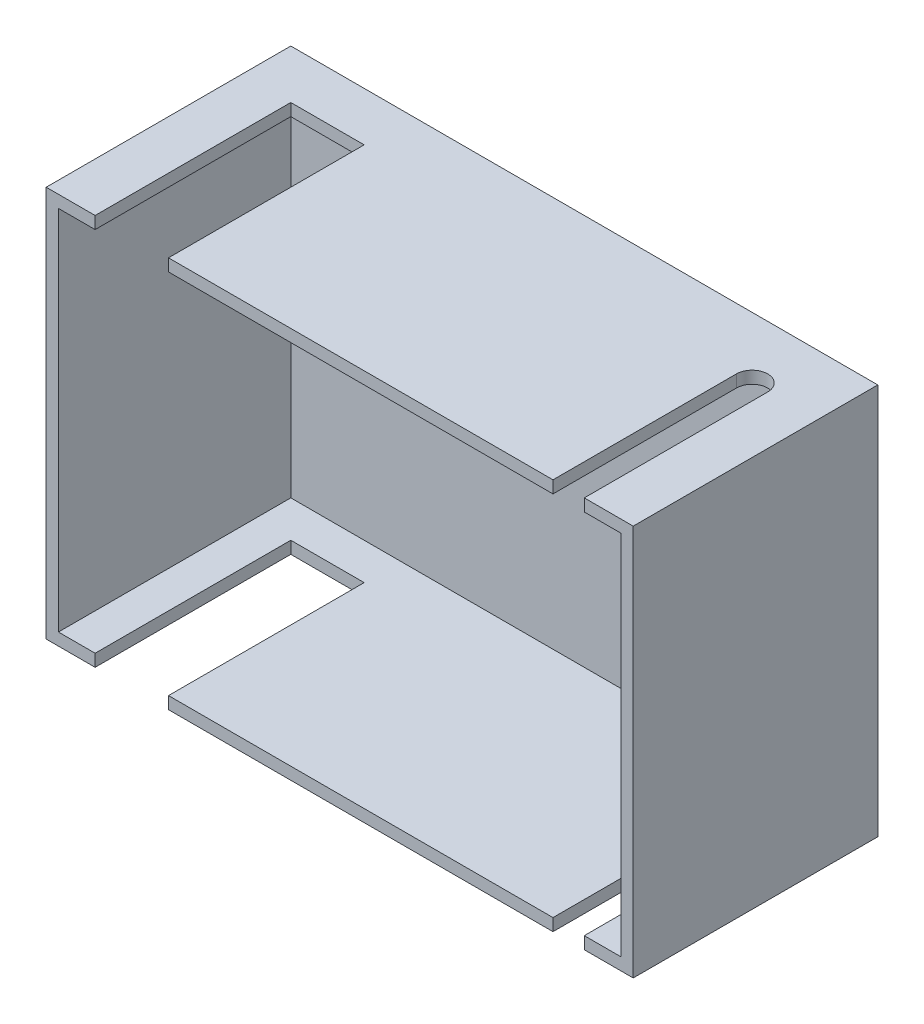
from build123d import *

# Parameters (mm, degrees)
SKETCH_1_W               = 120
SKETCH_1_H               = 80
EXTRUDE_1_DEPTH          = 50
SHELL_1_T                = -2.5
SKETCH_2_W               = 15
SKETCH_2_H               = 40
CUT_EXTRUDE_1_DEPTH      = 90
CUT_EXTRUDE_3_DEPTH      = 1
CUT_EXTRUDE_3_DEPTH_BACK = 81


with BuildPart() as part:
    # 草圖1 → 填料-伸長1 (new body)
    with BuildSketch(Plane.XY):
        Rectangle(SKETCH_1_W, SKETCH_1_H)
    extrude(amount=EXTRUDE_1_DEPTH)

    # 薄殼1
    shell_1_openings = [part.faces().sort_by_distance(p)[0] for p in [
        (0, 0, 50),
    ]]
    offset(amount=SHELL_1_T, openings=shell_1_openings, kind=Kind.INTERSECTION)

    # 草圖2 → 除料-伸長1 (cut)
    with BuildSketch(Plane.XZ.offset(40)):
        with Locations((-42.5, 30)):
            Rectangle(SKETCH_2_W, SKETCH_2_H)
    extrude(amount=-CUT_EXTRUDE_1_DEPTH, mode=Mode.SUBTRACT)

    # 草圖3 → 除料-伸長3 (cut, two sides)
    with BuildSketch(Plane.XZ.offset(40)) as cut_extrude_3_sk:
        with BuildLine():
            Line((43.6, 50), (43.6, 12.5))
            ThreePointArc((43.6, 12.5), (46.8, 9.3), (50, 12.5))
            Line((50, 12.5), (50, 50))
            Line((50, 50), (43.6, 50))
        make_face()
    extrude(amount=CUT_EXTRUDE_3_DEPTH, mode=Mode.SUBTRACT)
    extrude(cut_extrude_3_sk.sketch, amount=-CUT_EXTRUDE_3_DEPTH_BACK, mode=Mode.SUBTRACT)


solid = part.part
